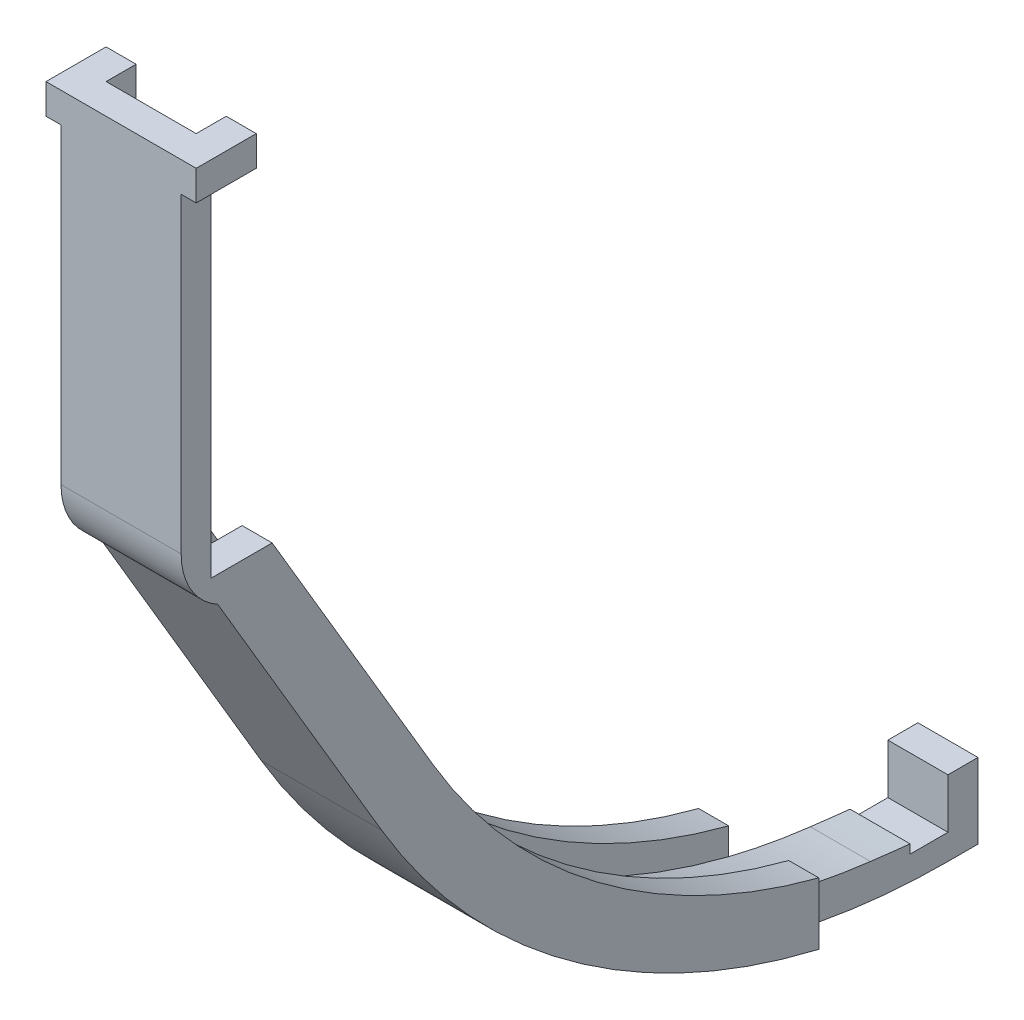
from build123d import *

# Parameters (mm, degrees)
SKETCH5_W           = 12.880016042
SKETCH5_H           = 15.834691301
CUT_EXTRUDE2_DEPTH  = 7.62
CUT_EXTRUDE6_REACH  = 62
SKETCH11_W          = 3.175
SKETCH11_H          = 3.175
BOSS_EXTRUDE1_DEPTH = 6.35
CUT_EXTRUDE4_DEPTH  = 3.175
SKETCH10_W          = 4
SKETCH10_H          = 0.5
CUT_EXTRUDE5_DEPTH  = 37.349999944
CUT_EXTRUDE7_DEPTH  = 40.64
BOSS_EXTRUDE3_DEPTH = 12.7
SKETCH19_W          = 21.319602533
SKETCH19_H          = 36.10119369
CUT_EXTRUDE10_DEPTH = 13.7
SKETCH15_W          = 6.35
SKETCH15_H          = 3.175
BOSS_EXTRUDE2_DEPTH = 1.5875
SKETCH17_W          = 3.175
SKETCH17_H          = 37.332237063
CUT_EXTRUDE9_DEPTH  = 20


with BuildPart() as part:
    # Sketch2 → Revolve1 (revolve)
    with BuildSketch(Plane(origin=(0, 0, 0), x_dir=(0, 0, -1), z_dir=(1, 0, 0))):
        Polygon((0, -50.8), (-29.999999944, 0), (0, 0), align=None)
    revolve(axis=Axis((0, 0, 0), (0, -1, 0)))

    # Sketch4 → Cut-Revolve1 (revolve, cut)
    with BuildSketch(Plane(origin=(0, 0, 0), x_dir=(0, 0, -1), z_dir=(1, 0, 0))):
        Polygon((0, -45.72), (-24.919999944, 0), (0, 0), align=None)
    revolve(axis=Axis((0, 16.11457811, 0), (0, -1, 0)), mode=Mode.SUBTRACT)

    # Sketch5 → Cut-Extrude2 (cut, symmetric)
    with BuildSketch(Plane(origin=(0, 0, 0), x_dir=(0, 0, -1), z_dir=(1, 0, 0))):
        with Locations((0, -47.812265381)):
            Rectangle(SKETCH5_W, SKETCH5_H)
    extrude(amount=CUT_EXTRUDE2_DEPTH, both=True, mode=Mode.SUBTRACT)

    # Sketch11 → Cut-Extrude6 (cut, up to next)
    with BuildSketch(Plane.XY.offset(29.999999944), mode=Mode.PRIVATE) as cut_extrude6_sk1:
        with Locations((4.7625, -1.5875)):
            Rectangle(SKETCH11_W, SKETCH11_H)
    cut_extrude6_tool1 = extrude(cut_extrude6_sk1.sketch, amount=-CUT_EXTRUDE6_REACH, mode=Mode.PRIVATE) & part.part
    add(cut_extrude6_tool1.solids().sort_by_distance((4.7625, -1.5875, 30))[0], mode=Mode.SUBTRACT)
    # Sketch11 → Cut-Extrude6 (cut, up to next)
    with BuildSketch(Plane.XY.offset(29.999999944), mode=Mode.PRIVATE) as cut_extrude6_sk2:
        with Locations((-4.7625, -1.5875)):
            Rectangle(SKETCH11_W, SKETCH11_H)
    cut_extrude6_tool2 = extrude(cut_extrude6_sk2.sketch, amount=-CUT_EXTRUDE6_REACH, mode=Mode.PRIVATE) & part.part
    add(cut_extrude6_tool2.solids().sort_by_distance((-4.7625, -1.5875, 30))[0], mode=Mode.SUBTRACT)

    # Sketch6 → Boss-Extrude1 (add, symmetric)
    with BuildSketch(Plane(origin=(0, 0, 0), x_dir=(0, 0, -1), z_dir=(1, 0, 0))):
        with BuildLine():
            Line((0, -39.89491973), (-7.374618631, -39.89491973))
            Line((-7.374618631, -39.89491973), (11.56279342, -71.962270863))
            ThreePointArc((11.56279342, -71.962270863), (29.890602823, -92.707185326), (54.61, -105.165575141))
            ThreePointArc((54.61, -105.165575141), (64.513552335, -107.250553005), (74.61, -107.95))
            Line((74.61, -107.95), (77.785, -107.95))
            Line((77.785, -107.95), (77.785, -100.0125))
            Line((77.785, -100.0125), (74.61, -100.0125))
            Line((74.61, -100.0125), (74.61, -101.6))
            ThreePointArc((74.61, -101.6), (41.460280796, -92.804941633), (17.03053379, -68.733290336))
            Line((17.03053379, -68.733290336), (0, -39.89491973))
        make_face()
        Polygon((-30.934610553, 0), (-7.374618631, -39.89491973), (0, -39.89491973), (-23.559991923, 0), align=None)
    extrude(amount=BOSS_EXTRUDE1_DEPTH, both=True)

    # Sketch7 → Cut-Extrude4 (cut)
    with BuildSketch(Plane(origin=(0, 0, 0), x_dir=(0, 0, -1), z_dir=(1, 0, 0))):
        with BuildLine():
            Line((-3.175, -39.89491973), (14.676503495, -70.123465704))
            ThreePointArc((14.676503495, -70.123465704), (36.599939349, -93.039017482), (66.414189392, -103.849662572))
            ThreePointArc((66.414189392, -103.849662572), (70.51080038, -104.32379518), (74.61, -104.775))
            Line((74.61, -104.775), (74.61, -101.6))
            ThreePointArc((74.61, -101.6), (59.345071166, -99.83437787), (44.886242604, -94.630749287))
            ThreePointArc((44.886242604, -94.630749287), (29.078331812, -83.704237641), (17.03053379, -68.733290336))
            Line((17.03053379, -68.733290336), (-23.559991923, 0))
            Line((-23.559991923, 0), (-26.734991923, 0))
            Line((-26.734991923, 0), (-3.175, -39.89491973))
        make_face()
    cut_extrude4 = extrude(amount=-CUT_EXTRUDE4_DEPTH, mode=Mode.SUBTRACT)

    # Mirror1: Cut-Extrude4 across plane
    add(cut_extrude4.mirror(Plane(origin=(0, 0, 0), x_dir=(0, 0, 1), z_dir=(1, 0, 0))), mode=Mode.SUBTRACT)

    # Sketch9 → Cut-Revolve2 (revolve, cut)
    with BuildSketch(Plane(origin=(0, 0, 0), x_dir=(0, 0, -1), z_dir=(1, 0, 0))):
        Polygon((0, 0), (-24.9199908, 0), (-0.536470716, -39.89491973), (0, -39.89491973), align=None)
    revolve(axis=Axis((0, 16.11457811, 0), (0, -1, 0)), mode=Mode.SUBTRACT)

    # Sketch10 → Cut-Extrude5 (cut, through all)
    with BuildSketch(Plane.ZY.offset(6.35)):
        with BuildLine():
            Line((-70.61, -104.775), (-70.61, -101.480258272))
            ThreePointArc((-70.61, -101.480258272), (-72.609104071, -101.570057864), (-74.61, -101.6))
            Line((-74.61, -101.6), (-74.61, -104.775))
            Line((-74.61, -104.775), (-70.61, -104.775))
        make_face()
        with Locations((-72.61, -105.025)):
            Rectangle(SKETCH10_W, SKETCH10_H)
    extrude(amount=-CUT_EXTRUDE5_DEPTH, mode=Mode.SUBTRACT)

    # Sketch12 → Cut-Extrude7 (cut, symmetric)
    with BuildSketch(Plane.ZY):
        Polygon((30, 0), (-61.025869449, 0), (-61.025869449, -39.89491973), (-6.440008021, -39.89491973), (6.44000802, -39.89491973), (27.945214206, -3.175), align=None)
    extrude(amount=CUT_EXTRUDE7_DEPTH, both=True, mode=Mode.SUBTRACT)

    # Sketch18 → Boss-Extrude3 (add)
    with BuildSketch(Plane.ZY.offset(6.35)):
        with BuildLine():
            Line((6.44000802, -39.89491973), (6.44000802, 0))
            Line((6.44000802, 0), (9.61500802, 0))
            Line((9.61500802, 0), (9.61500802, -34.473639686))
            Line((9.61500802, -34.473639686), (9.61500802, -36.10119369))
            ThreePointArc((9.61500802, -36.10119369), (8.57844205, -39.89491973), (5.756782033, -42.634456374))
            Line((5.756782033, -42.634456374), (6.44000802, -41.477527034))
            Line((6.44000802, -41.477527034), (6.44000802, -39.89491973))
        make_face()
    extrude(amount=-BOSS_EXTRUDE3_DEPTH)

    # Sketch19 → Cut-Extrude10 (cut, through all)
    with BuildSketch(Plane.ZY.offset(6.35)):
        with Locations((20.274809287, -18.050596845)):
            Rectangle(SKETCH19_W, SKETCH19_H)
    extrude(amount=-CUT_EXTRUDE10_DEPTH, mode=Mode.SUBTRACT)

    # Sketch15 → Boss-Extrude2 (add, symmetric)
    with BuildSketch(Plane.ZY.offset(6.35)):
        with Locations((6.44000802, -1.5875)):
            Rectangle(SKETCH15_W, SKETCH15_H)
    boss_extrude2 = extrude(amount=BOSS_EXTRUDE2_DEPTH, both=True)

    # Mirror2: Boss-Extrude2 across plane
    add(boss_extrude2.mirror(Plane(origin=(0, 0, 0), x_dir=(0, 0, 1), z_dir=(1, 0, 0))))

    # Sketch17 → Cut-Extrude9 (cut)
    with BuildSketch(Plane(origin=(0, 0, -77.785), x_dir=(-1, 0, 0), z_dir=(0, 0, -1))):
        with Locations((-4.7625, -89.283881468)):
            Rectangle(SKETCH17_W, SKETCH17_H)
        with Locations((4.7625, -89.283881468)):
            Rectangle(SKETCH17_W, SKETCH17_H)
    extrude(amount=-CUT_EXTRUDE9_DEPTH, mode=Mode.SUBTRACT)


solid = part.part
